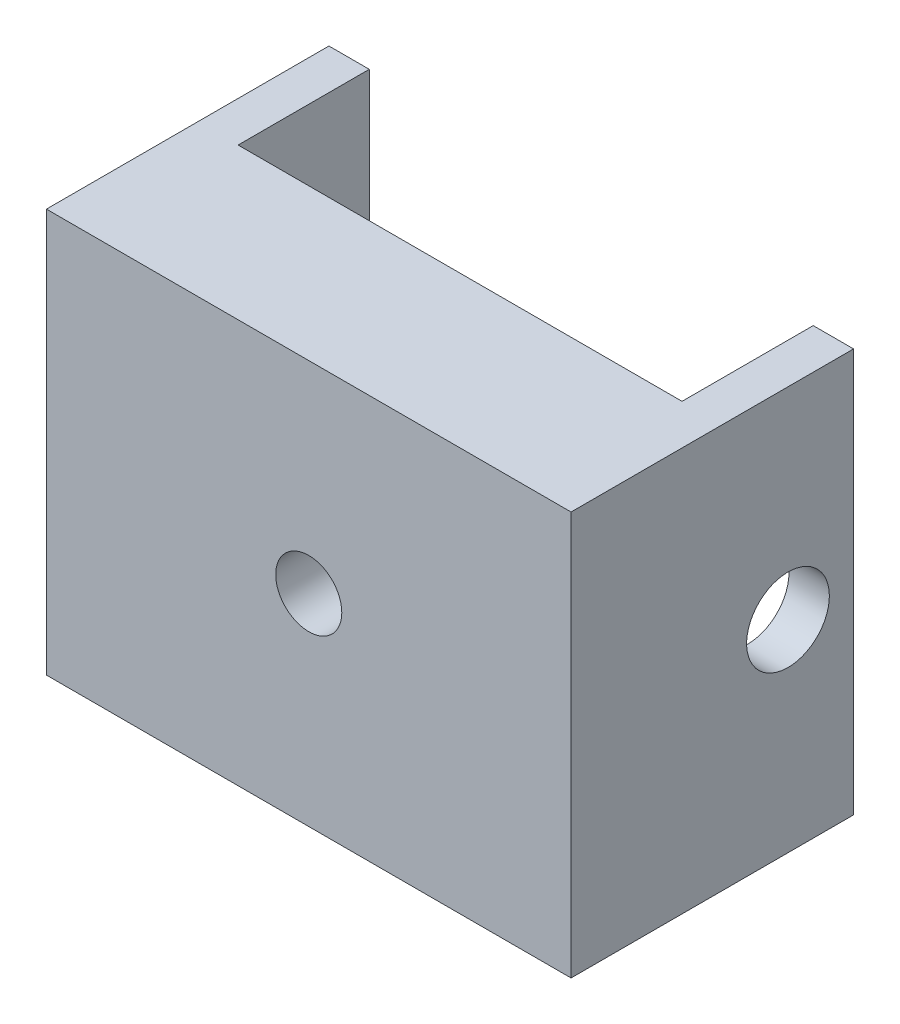
from build123d import *

# Parameters (mm, degrees)
BOSS_EXTRUDE1_DEPTH     = 20
SKETCH3_R               = 1.6375
CUT_EXTRUDE1_DEPTH      = 6
CUT_EXTRUDE1_DEPTH_BACK = 10
SKETCH7_R               = 2.05
CUT_EXTRUDE2_DEPTH      = 14
CUT_EXTRUDE2_DEPTH_BACK = 14


with BuildPart() as part:
    # Sketch1 → Boss-Extrude1 (new body)
    with BuildSketch(Plane(origin=(0, 0, 0), x_dir=(1, 0, 0), z_dir=(0, 1, 0))):
        Polygon((13, -5), (13, 9), (11, 9), (11, 2.5), (-11, 2.5), (-11, 9), (-13, 9), (-13, -5), align=None)
    extrude(amount=BOSS_EXTRUDE1_DEPTH)

    # Sketch3 → Cut-Extrude1 (cut, two sides)
    with BuildSketch(Plane.XY) as cut_extrude1_sk:
        with Locations((0, 10)):
            Circle(SKETCH3_R)
    extrude(amount=CUT_EXTRUDE1_DEPTH, mode=Mode.SUBTRACT)
    extrude(cut_extrude1_sk.sketch, amount=-CUT_EXTRUDE1_DEPTH_BACK, mode=Mode.SUBTRACT)

    # Sketch7 → Cut-Extrude2 (cut, two sides)
    with BuildSketch(Plane(origin=(0, 0, 0), x_dir=(0, 0, -1), z_dir=(1, 0, 0))) as cut_extrude2_sk:
        with Locations((5.75, 10)):
            Circle(SKETCH7_R)
    extrude(amount=CUT_EXTRUDE2_DEPTH, mode=Mode.SUBTRACT)
    extrude(cut_extrude2_sk.sketch, amount=-CUT_EXTRUDE2_DEPTH_BACK, mode=Mode.SUBTRACT)


solid = part.part
